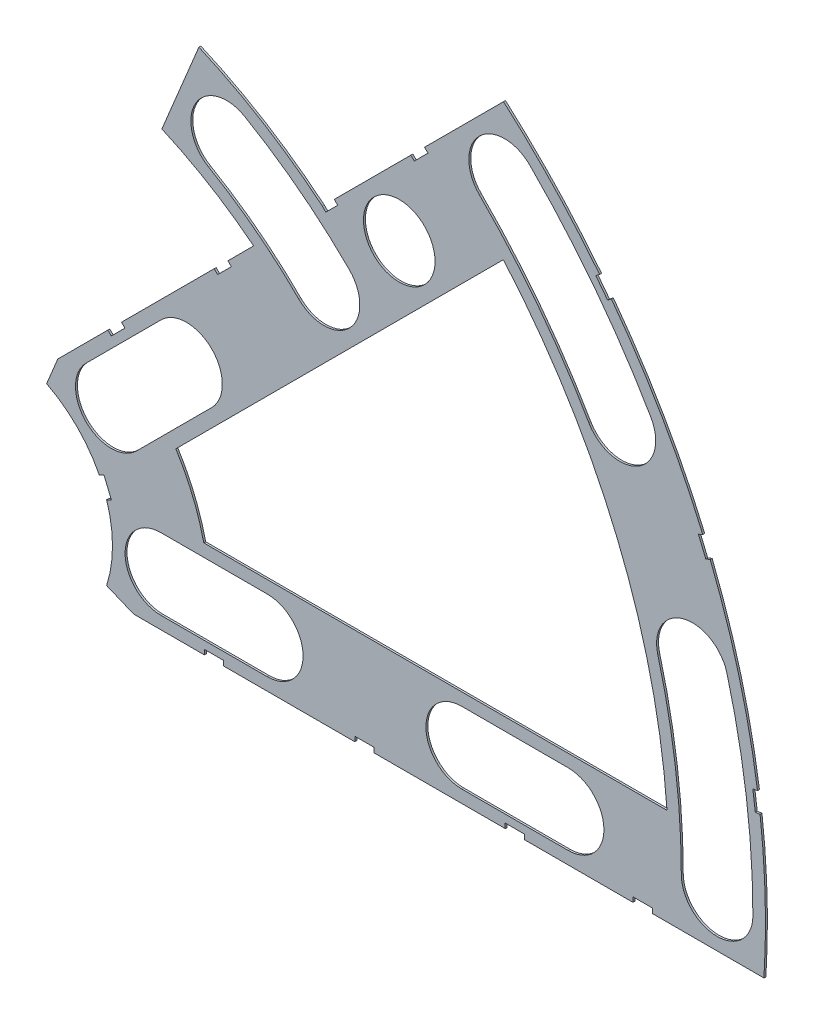
from build123d import *

# Parameters (mm, degrees)
BOSS_EXTRUDE1_DEPTH = 0.254
SKETCH2_R           = 4.699
CUT_EXTRUDE1_DEPTH  = 1.254
SKETCH3_W           = 2.54
SKETCH3_H           = 0.635
CUT_EXTRUDE2_DEPTH  = 1.254
CUT_EXTRUDE3_DEPTH  = 1.254


with BuildPart() as part:
    # Sketch1 → Boss-Extrude1 (new body)
    with BuildSketch(Plane.XY):
        with BuildLine():
            Line((27.218819563, 62.393373411), (22.357699804, 50.65759216))
            ThreePointArc((22.357699804, 50.65759216), (28.61353693, 47.405947816), (34.405475059, 43.38573118))
            Line((34.405475059, 43.38573118), (8.696654013, 17.676910134))
            Line((8.696654013, 17.676910134), (7.228954972, 14.133571205))
            ThreePointArc((7.228954972, 14.133571205), (14.666587579, 6.075099489), (15.105587123, -4.88230096))
            Line((15.105587123, -4.88230096), (18.648926052, -6.35))
            Line((18.648926052, -6.35), (101.401368334, -6.35))
            ThreePointArc((101.401368334, -6.35), (93.866160503, 38.880636728), (67.21146711, 76.191723231))
            Line((67.21146711, 76.191723231), (43.43415954, 52.414415661))
            ThreePointArc((43.43415954, 52.414415661), (35.677104191, 57.973626939), (27.218819563, 62.393373411))
        make_face()
        with BuildLine():
            Line((88.672924278, 6.35), (27.86051193, 6.35))
            ThreePointArc((27.86051193, 6.35), (26.399857642, 10.93517908), (24.190484974, 15.210228852))
            Line((24.190484974, 15.210228852), (67.191354125, 58.211098004))
            ThreePointArc((67.191354125, 58.211098004), (82.13289044, 34.020557137), (88.672924278, 6.35))
        make_face(mode=Mode.SUBTRACT)
    extrude(amount=BOSS_EXTRUDE1_DEPTH)

    # Sketch2 → Cut-Extrude1 (cut, through all)
    with BuildSketch(Plane.XY.offset(0.254)):
        with Locations((22.225, 0)):
            Circle(SKETCH2_R)
        with Locations((36.195, 0)):
            Circle(SKETCH2_R)
        with Locations((61.722, 0)):
            Circle(SKETCH2_R)
        with Locations((75.692, 0)):
            Circle(SKETCH2_R)
        with Locations((95.25, 0)):
            Circle(SKETCH2_R)
        with Locations((15.715448212, 15.715448212)):
            Circle(SKETCH2_R)
        with Locations((25.593729945, 25.593729945)):
            Circle(SKETCH2_R)
        with Locations((43.644044748, 43.644044748)):
            Circle(SKETCH2_R)
        with Locations((53.522326482, 53.522326482)):
            Circle(SKETCH2_R)
        with Locations((92.004434954, 24.652514046)):
            Circle(SKETCH2_R)
        with Locations((82.48891971, 47.625)):
            Circle(SKETCH2_R)
        with Locations((67.351920908, 67.351920908)):
            Circle(SKETCH2_R)
        with Locations((30.861, 53.452819972)):
            Circle(SKETCH2_R)
    extrude(amount=-CUT_EXTRUDE1_DEPTH, mode=Mode.SUBTRACT)

    # Sketch3 → Cut-Extrude2 (cut, through all)
    with BuildSketch(Plane.XY.offset(0.254)):
        Polygon((15.266435406, 24.246691527), (17.06248663, 26.042742751), (17.511499436, 25.593729945), (15.715448212, 23.797678721), align=None)
        Polygon((43.43415954, 52.414415661), (44.991083167, 53.971339288), (45.440095973, 53.522326482), (43.883172346, 51.965402855), align=None)
        with Locations((29.21, -6.0325)):
            Rectangle(SKETCH3_W, SKETCH3_H)
        with Locations((68.707, -6.0325)):
            Rectangle(SKETCH3_W, SKETCH3_H)
        Polygon((29.230733674, 38.210989795), (31.026784898, 40.007041019), (31.475797704, 39.558028213), (29.67974648, 37.761976989), align=None)
        Polygon((56.845021246, 65.825277367), (55.048970022, 64.029226143), (55.497982828, 63.580213337), (57.294034052, 65.376264561), align=None)
        with Locations((48.9585, -6.0325)):
            Rectangle(SKETCH3_W, SKETCH3_H)
        with Locations((85.471, -6.0325)):
            Rectangle(SKETCH3_W, SKETCH3_H)
        Polygon((99.935462164, 14.437711971), (100.266998693, 11.919442024), (101.526133667, 12.085210288), (101.194597138, 14.603480236), align=None)
        Polygon((93.765504959, 37.464305742), (94.938831965, 37.950313702), (93.966816047, 40.296967714), (92.793489041, 39.810959755), align=None)
        Polygon((79.327792988, 62.471156422), (80.874047017, 60.456038938), (81.88160576, 61.229165953), (80.33535173, 63.244283437), align=None)
        Polygon((13.593916116, 7.005422516), (14.565932035, 4.658768503), (15.739259041, 5.144776462), (14.767243123, 7.491430475), align=None)
    extrude(amount=-CUT_EXTRUDE2_DEPTH, mode=Mode.SUBTRACT)

    # Sketch7 → Cut-Extrude3 (cut, through all)
    with BuildSketch(Plane.XY.offset(0.254)):
        with BuildLine():
            Line((12.392753447, 19.038142977), (22.27103518, 28.91642471))
            ThreePointArc((22.27103518, 28.91642471), (28.91642471, 28.91642471), (28.91642471, 22.27103518))
            Line((28.91642471, 22.27103518), (19.038142977, 12.392753447))
            ThreePointArc((19.038142977, 12.392753447), (12.392753447, 12.392753447), (12.392753447, 19.038142977))
        make_face()
        with BuildLine():
            Line((22.225, 4.699), (36.195, 4.699))
            ThreePointArc((36.195, 4.699), (40.894, 0), (36.195, -4.699))
            Line((36.195, -4.699), (22.225, -4.699))
            ThreePointArc((22.225, -4.699), (17.526, 0), (22.225, 4.699))
        make_face()
        with BuildLine():
            Line((61.722, 4.699), (75.692, 4.699))
            ThreePointArc((75.692, 4.699), (80.391, 0), (75.692, -4.699))
            Line((75.692, -4.699), (61.722, -4.699))
            ThreePointArc((61.722, -4.699), (57.023, 0), (61.722, 4.699))
        make_face()
        with BuildLine():
            ThreePointArc((46.966739513, 46.966739513), (40.434542876, 52.695322215), (33.2105, 57.522273345))
            ThreePointArc((33.2105, 57.522273345), (26.791546628, 55.802319972), (28.5115, 49.3833666))
            ThreePointArc((28.5115, 49.3833666), (34.713402966, 45.239387523), (40.321349984, 40.321349984))
            ThreePointArc((40.321349984, 40.321349984), (46.966739513, 40.321349984), (46.966739513, 46.966739513))
        make_face()
        with BuildLine():
            ThreePointArc((99.949, 0), (99.093922449, 13.045962386), (96.543320412, 25.868704739))
            ThreePointArc((96.543320412, 25.868704739), (90.788244261, 29.191399504), (87.465549496, 23.436323353))
            ThreePointArc((87.465549496, 23.436323353), (89.776323642, 11.819277232), (90.551, 0))
            ThreePointArc((90.551, 0), (95.25, -4.699), (99.949, 0))
        make_face()
        with BuildLine():
            ThreePointArc((86.558373083, 49.9745), (79.294873009, 60.845096068), (70.674615673, 70.674615673))
            ThreePointArc((70.674615673, 70.674615673), (64.029226143, 70.674615673), (64.029226143, 64.029226143))
            ThreePointArc((64.029226143, 64.029226143), (71.838938317, 55.123956158), (78.419466338, 45.2755))
            ThreePointArc((78.419466338, 45.2755), (84.83841971, 43.555546628), (86.558373083, 49.9745))
        make_face()
    extrude(amount=-CUT_EXTRUDE3_DEPTH, mode=Mode.SUBTRACT)


solid = part.part
